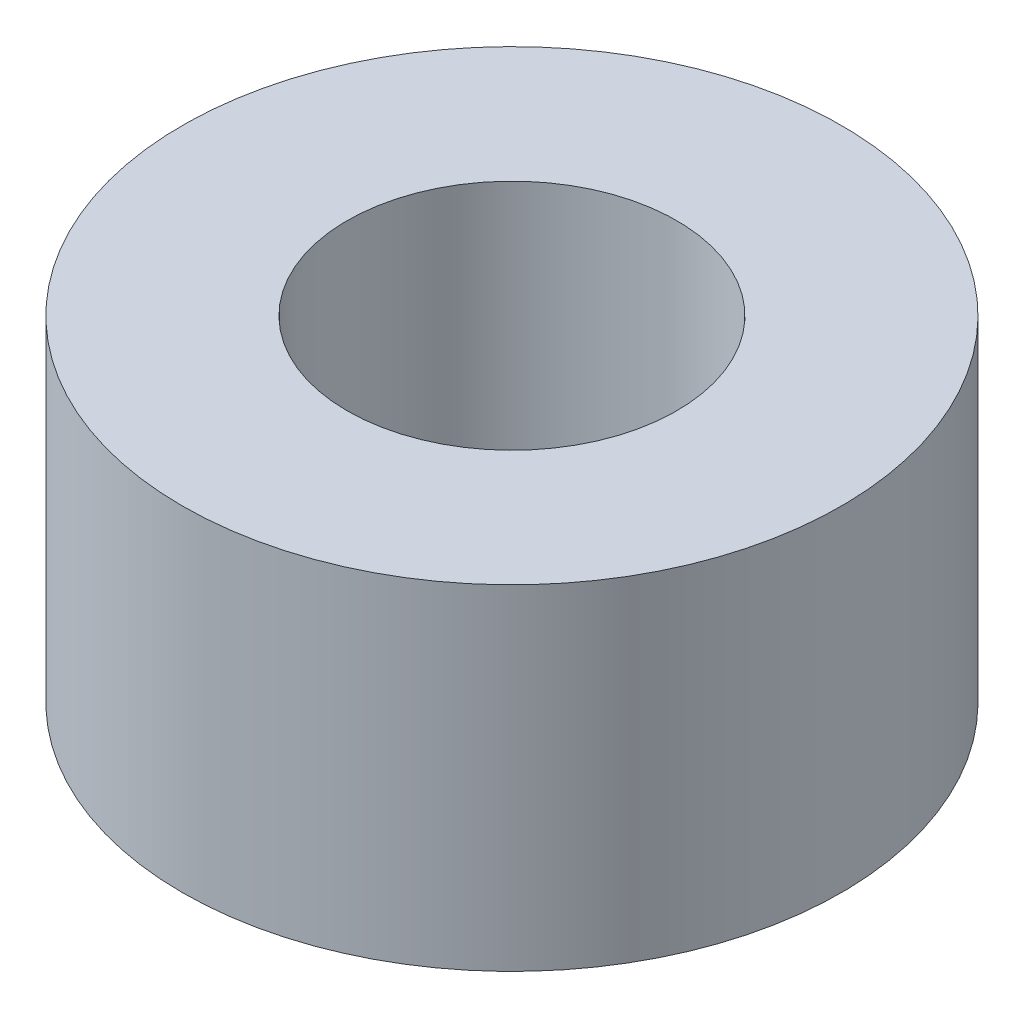
from build123d import *

# Parameters (mm, degrees)
SKETCH1_R           = 2.5
SKETCH1_R_2         = 1.25
BOSS_EXTRUDE1_DEPTH = 2.54


with BuildPart() as part:
    # Sketch1 → Boss-Extrude1 (new body)
    with BuildSketch(Plane(origin=(0, 0, 0), x_dir=(1, 0, 0), z_dir=(0, 1, 0))):
        Circle(SKETCH1_R)
        Circle(SKETCH1_R_2, mode=Mode.SUBTRACT)
    extrude(amount=BOSS_EXTRUDE1_DEPTH)


solid = part.part
